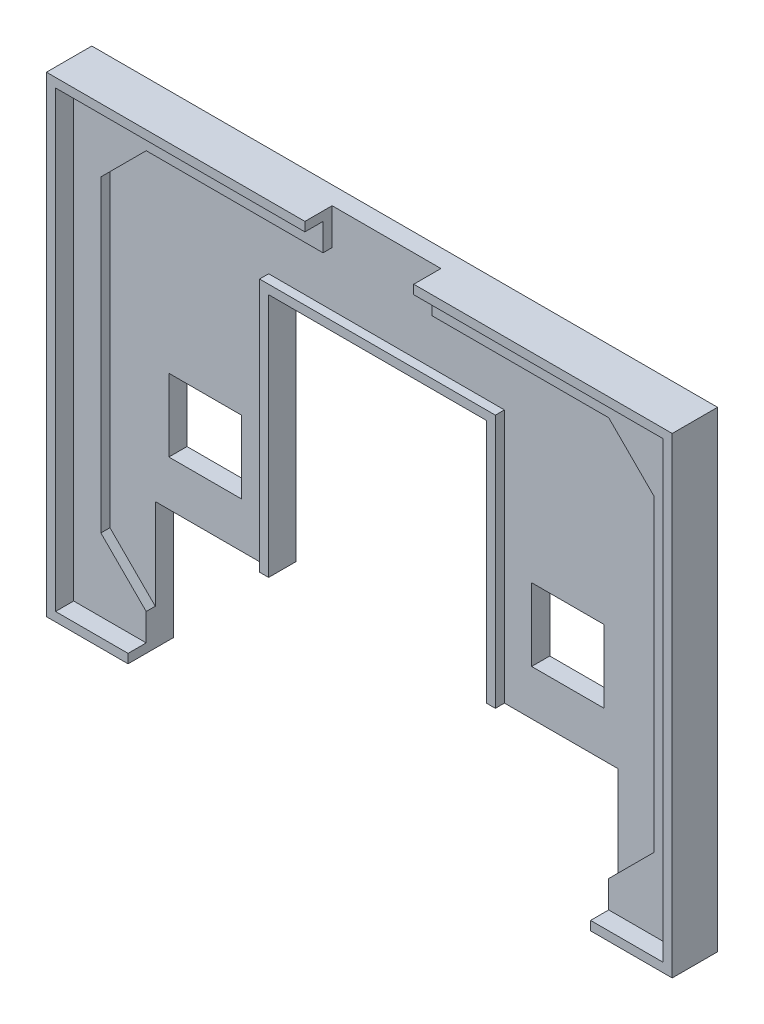
from build123d import *

# Parameters (mm, degrees)
SKICA1_W                    = 67
SKICA1_H                    = 50
P_IDAT_VYSUNUT_M1_DEPTH     = 3
ODEBRAT_VYSUNUT_M1_DEPTH    = 1
SKICA3_W                    = 8
SKICA3_H                    = 8
ODEBRAT_VYSUNUT_M2_DEPTH    = 4
VYSUNOUT_TENKOST_NN_1_DEPTH = 1
VYSUNOUT_TENKOST_NN_2_DEPTH = 5
SKICA6_W                    = 12
SKICA6_H                    = 4
ODEBRAT_VYSUNUT_M3_DEPTH    = 4
ODEBRAT_VYSUNUT_M5_DEPTH    = 1
P_IDAT_START                = -1
P_IDAT_VYSUNUT_M3_DEPTH     = 1
ODEBRAT_VYSUNUT_M7_DEPTH    = 1
SKICA10_W                   = 1.6
SKICA10_H                   = 4
SKICA10_H_2                 = 1.6
P_IDAT_VYSUNUT_M4_DEPTH     = 1


with BuildPart() as part:
    # Skica1 → Přidat vysunutím1 (new body)
    with BuildSketch(Plane.XY):
        Rectangle(SKICA1_W, SKICA1_H)
    extrude(amount=P_IDAT_VYSUNUT_M1_DEPTH)

    # Skica2 → Odebrat vysunutím1 (cut)
    with BuildSketch(Plane.XY.offset(3)):
        Polygon((-25.5, -22), (-30.5, -17), (-30.5, 17), (-25.5, 22), (25.5, 22), (30.5, 17), (30.5, -17), (25.5, -22), align=None)
    extrude(amount=-ODEBRAT_VYSUNUT_M1_DEPTH, mode=Mode.SUBTRACT)

    # Skica3 → Odebrat vysunutím2 (cut, through all)
    with BuildSketch(Plane(origin=(0, 0, 0), x_dir=(-1, 0, 0), z_dir=(0, 0, -1))):
        with Locations((20, -3)):
            Rectangle(SKICA3_W, SKICA3_H)
        with Locations((-20, -3)):
            Rectangle(SKICA3_W, SKICA3_H)
        Polygon((25.5, -25), (-25.5, -25), (-25.5, -12), (-12, -12), (-12, 15), (12, 15), (12, -12), (25.5, -12), align=None)
    extrude(amount=-ODEBRAT_VYSUNUT_M2_DEPTH, mode=Mode.SUBTRACT)

    # Skica4 → Vysunout tenkostěnný1 (add)
    with BuildSketch(Plane.XY.offset(2)):
        Polygon((-12, -12), (-12, 15), (12, 15), (12, -12), (13, -12), (13, 16), (-13, 16), (-13, -12), align=None)
    extrude(amount=VYSUNOUT_TENKOST_NN_1_DEPTH)

    # Skica5 → Vysunout tenkostěnný2 (add)
    with BuildSketch(Plane(origin=(0, 0, 0), x_dir=(-1, 0, 0), z_dir=(0, 0, -1))):
        Polygon((-25.5, -25), (-33.5, -25), (-33.5, 25), (33.5, 25), (33.5, -25), (25.5, -25), (25.5, -26), (34.5, -26), (34.5, 26), (-34.5, 26), (-34.5, -26), (-25.5, -26), align=None)
    extrude(amount=-VYSUNOUT_TENKOST_NN_2_DEPTH)

    # Skica6 → Odebrat vysunutím3 (cut, through all)
    with BuildSketch(Plane.XY.offset(2)):
        with Locations((0, 24)):
            Rectangle(SKICA6_W, SKICA6_H)
    extrude(amount=ODEBRAT_VYSUNUT_M3_DEPTH, mode=Mode.SUBTRACT)

    # Skica7 → Odebrat vysunutím5 (cut)
    with BuildSketch(Plane(origin=(0, 0, 0), x_dir=(-1, 0, 0), z_dir=(0, 0, -1))):
        Polygon((-32.44, 14.540476732), (-23.459523268, 23.94), (-14.06, 14.959523268), (-23.040476732, 5.56), align=None)
        Polygon((14.06, 14.959523268), (23.040476732, 5.56), (32.44, 14.540476732), (23.459523268, 23.94), align=None)
    extrude(amount=-ODEBRAT_VYSUNUT_M5_DEPTH, mode=Mode.SUBTRACT)

    # Skica8 → Přidat vysunutím3 (add)
    with BuildSketch(Plane(origin=(0, 0, 0), x_dir=(-1, 0, 0), z_dir=(0, 0, -1)).offset(P_IDAT_START)):
        Polygon((-29.266904741, 14.966465555), (-27.459304113, 13.239450799), (-25.732289356, 15.047051428), (-27.539889985, 16.774066184), align=None)
        Polygon((-25.467472278, 18.943186938), (-23.659871649, 17.216172182), (-21.932856893, 19.023772811), (-23.740457522, 20.750787567), align=None)
        Polygon((-18.333772811, 16.276666375), (-24.551025932, 9.769304113), (-26.358626561, 11.496318869), (-20.141373439, 18.003681131), align=None)
        Polygon((21.932856893, 19.023772811), (23.740457522, 20.750787567), (25.467472278, 18.943186938), (23.659871649, 17.216172182), align=None)
        Polygon((25.732289356, 15.047051428), (27.539889985, 16.774066184), (29.266904741, 14.966465555), (27.459304113, 13.239450799), align=None)
        Polygon((18.333772811, 16.276666375), (24.551025932, 9.769304113), (26.358626561, 11.496318869), (20.141373439, 18.003681131), align=None)
    extrude(amount=P_IDAT_VYSUNUT_M3_DEPTH)

    # Skica9 → Odebrat vysunutím7 (cut)
    with BuildSketch(Plane(origin=(0, 0, 0), x_dir=(-1, 0, 0), z_dir=(0, 0, -1))):
        Polygon((-10.8, 23.3), (-6.8, 23.3), (-6.8, 22.5), (-6, 22.5), (-6, 18.5), (-6.8, 18.5), (-6.8, 17.7), (-10.8, 17.7), align=None)
        Polygon((-4.4, 23.3), (-1.2, 23.3), (-1.2, 22.5), (-0.4, 22.5), (-0.4, 17.7), (-2, 17.7), (-2, 20.1), (-3.6, 20.1), (-3.6, 17.7), (-5.2, 17.7), (-5.2, 22.5), (-4.4, 22.5), align=None)
        Polygon((1.2, 23.3), (4.4, 23.3), (4.4, 22.5), (5.2, 22.5), (5.2, 21.7), (3.6, 21.7), (3.6, 22.49542164), (2, 22.49542164), (2, 20.89542164), (4.4, 20.89542164), (4.4, 20.09542164), (5.2, 20.09542164), (5.2, 18.5), (4.4, 18.5), (4.4, 17.7), (1.2, 17.7), (1.2, 18.5), (0.4, 18.5), (0.4, 19.3), (2, 19.3), (2, 18.5), (3.6, 18.5), (3.6, 20.09542164), (1.2, 20.09542164), (1.2, 20.9), (0.4, 20.9), (0.4, 22.5), (1.2, 22.5), align=None)
        Polygon((6, 23.3), (7.6, 23.3), (7.6, 20.9), (9.2, 20.9), (9.2, 23.3), (10.8, 23.3), (10.8, 17.7), (9.2, 17.7), (9.2, 20.1), (7.6, 20.1), (7.6, 17.7), (6, 17.7), align=None)
    extrude(amount=-ODEBRAT_VYSUNUT_M7_DEPTH, mode=Mode.SUBTRACT)

    # Skica10 → Přidat vysunutím4 (add)
    with BuildSketch(Plane(origin=(0, 0, 0), x_dir=(-1, 0, 0), z_dir=(0, 0, -1)).offset(P_IDAT_START)):
        with Locations((-8.4, 20.5)):
            Rectangle(SKICA10_W, SKICA10_H)
        with Locations((-2.8, 21.7)):
            Rectangle(SKICA10_W, SKICA10_H_2)
    extrude(amount=P_IDAT_VYSUNUT_M4_DEPTH)


solid = part.part
